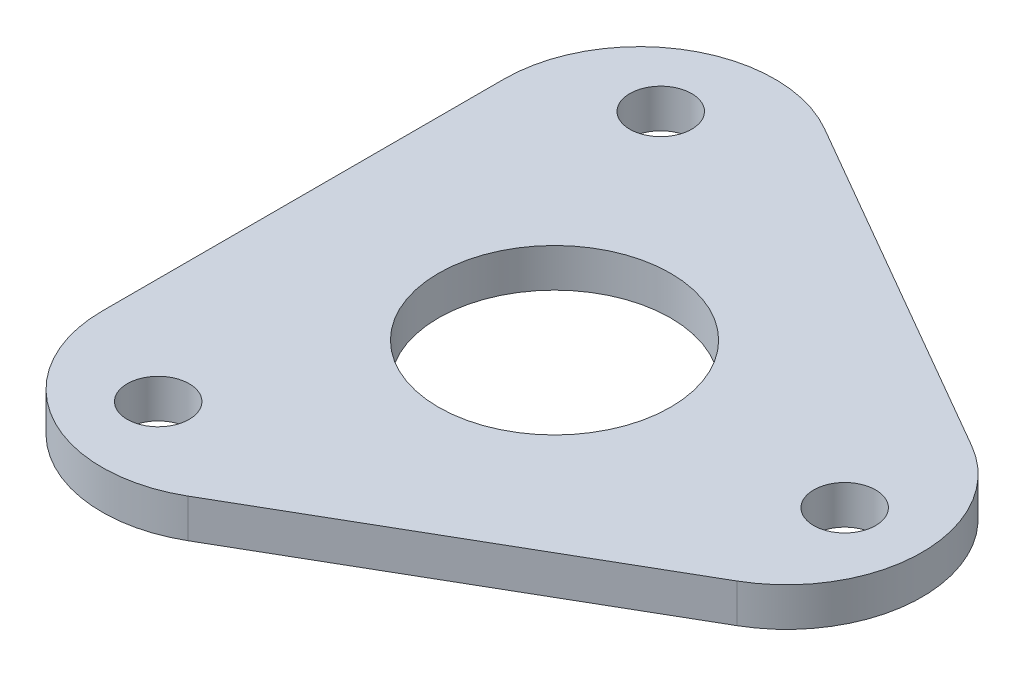
from build123d import *

# Parameters (mm, degrees)
SKETCH1_R           = 1.6
SKETCH1_R_2         = 6
BOSS_EXTRUDE1_DEPTH = 2
FILLET1_R           = 7


with BuildPart() as part:
    # Sketch1 → Boss-Extrude1 (new body)
    with BuildSketch(Plane(origin=(0, 0, 0), x_dir=(1, 0, 0), z_dir=(0, 1, 0))):
        Polygon((26, 0), (-13, 22.516660498), (-13, -22.516660498), align=None)
        with Locations((-7.5, 12.990381057)):
            Circle(SKETCH1_R, mode=Mode.SUBTRACT)
        with Locations((15, 0)):
            Circle(SKETCH1_R, mode=Mode.SUBTRACT)
        with Locations((-7.5, -12.990381057)):
            Circle(SKETCH1_R, mode=Mode.SUBTRACT)
        Circle(SKETCH1_R_2, mode=Mode.SUBTRACT)
    extrude(amount=BOSS_EXTRUDE1_DEPTH)

    # Fillet1
    fillet1_edges = [part.edges().sort_by_distance(p)[0] for p in [
        (-13, 1, 22.516660498),
        (-13, 1, -22.516660498),
        (26, 1, 0),
    ]]
    fillet(fillet1_edges, radius=FILLET1_R)


solid = part.part
